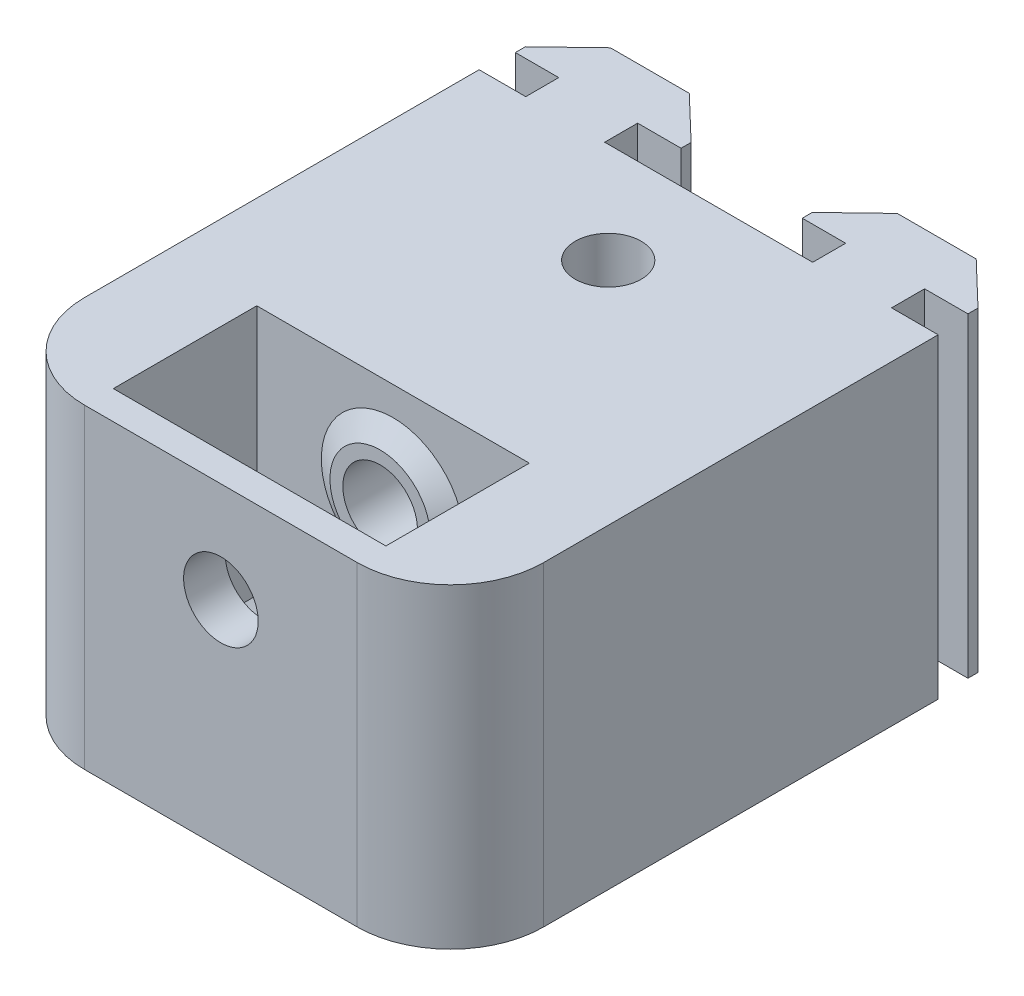
from build123d import *

# Parameters (mm, degrees)
SKETCH1_R           = 2.3
SKETCH1_W           = 19
SKETCH1_H           = 10
BOSS_EXTRUDE1_DEPTH = 22
BOSS_EXTRUDE2_REACH = 39.9
SKETCH5_R           = 2.6
CUT_EXTRUDE1_DEPTH  = 17.5


with BuildPart() as part:
    # Sketch1 → Boss-Extrude1 (new body)
    with BuildSketch(Plane(origin=(0, 0, 0), x_dir=(1, 0, 0), z_dir=(0, 1, 0))):
        with BuildLine():
            Line((-32, 0), (-32, -27.5))
            ThreePointArc((-32, -27.5), (-30.096194078, -32.096194078), (-25.5, -34))
            Line((-25.5, -34), (-6.5, -34))
            ThreePointArc((-6.5, -34), (-1.903805922, -32.096194078), (0, -27.5))
            Line((0, -27.5), (0, 0))
            Line((0, 0), (-3.25, 0))
            Line((-3.25, 0), (-3.25, 2.3))
            Line((-3.25, 2.3), (-0.225, 2.3))
            Line((-0.225, 2.3), (-0.225, 3))
            Line((-0.225, 3), (-3.25, 5.9))
            Line((-3.25, 5.9), (-8.75, 5.9))
            Line((-8.75, 5.9), (-11.775, 3))
            Line((-11.775, 3), (-11.775, 2.3))
            Line((-11.775, 2.3), (-8.75, 2.3))
            Line((-8.75, 2.3), (-8.75, 0))
            Line((-8.75, 0), (-23.25, 0))
            Line((-23.25, 0), (-23.25, 2.3))
            Line((-23.25, 2.3), (-20.225, 2.3))
            Line((-20.225, 2.3), (-20.225, 3))
            Line((-20.225, 3), (-23.25, 5.9))
            Line((-23.25, 5.9), (-28.75, 5.9))
            Line((-28.75, 5.9), (-31.775, 3))
            Line((-31.775, 3), (-31.775, 2.3))
            Line((-31.775, 2.3), (-28.75, 2.3))
            Line((-28.75, 2.3), (-28.75, 0))
            Line((-28.75, 0), (-32, 0))
        make_face()
        with Locations((-16, -7)):
            Circle(SKETCH1_R, mode=Mode.SUBTRACT)
        with Locations((-16, -27)):
            Rectangle(SKETCH1_W, SKETCH1_H, mode=Mode.SUBTRACT)
    extrude(amount=BOSS_EXTRUDE1_DEPTH)

    # Sketch2 → Boss-Extrude2 (add, up to next)
    with BuildSketch(Plane(origin=(0, 0, 32), x_dir=(-1, 0, 0), z_dir=(0, 0, -1)), mode=Mode.PRIVATE) as boss_extrude2_sk1:
        with BuildLine():
            Line((21.5, 0), (21.5, 8.519259302))
            ThreePointArc((21.5, 8.519259302), (16, 6.5), (10.5, 8.519259302))
            Line((10.5, 8.519259302), (10.5, 0))
            Line((10.5, 0), (21.5, 0))
        make_face()
    boss_extrude2_tool1 = extrude(boss_extrude2_sk1.sketch, amount=BOSS_EXTRUDE2_REACH, mode=Mode.PRIVATE) - part.part
    add(boss_extrude2_tool1.solids().sort_by_distance((-16, 3.593056, 32))[0])

    # Sketch4 → Revolve1 (revolve)
    with BuildSketch(Plane(origin=(-16, 0, 0), x_dir=(0, 0, -1), z_dir=(1, 0, 0))):
        Polygon((-32, 20), (-31.1, 18.5), (-31.1, 15), (-32, 15), align=None)
        Polygon((-22, 15), (-22.9, 15), (-22.9, 18.5), (-22, 20), align=None)
    revolve(axis=Axis((-16, 15, 32), (0, 0, -1)))

    # Sketch5 → Cut-Extrude1 (cut)
    with BuildSketch(Plane.XY.offset(34)):
        with Locations((-16, 15)):
            Circle(SKETCH5_R)
    extrude(amount=-CUT_EXTRUDE1_DEPTH, mode=Mode.SUBTRACT)


solid = part.part
